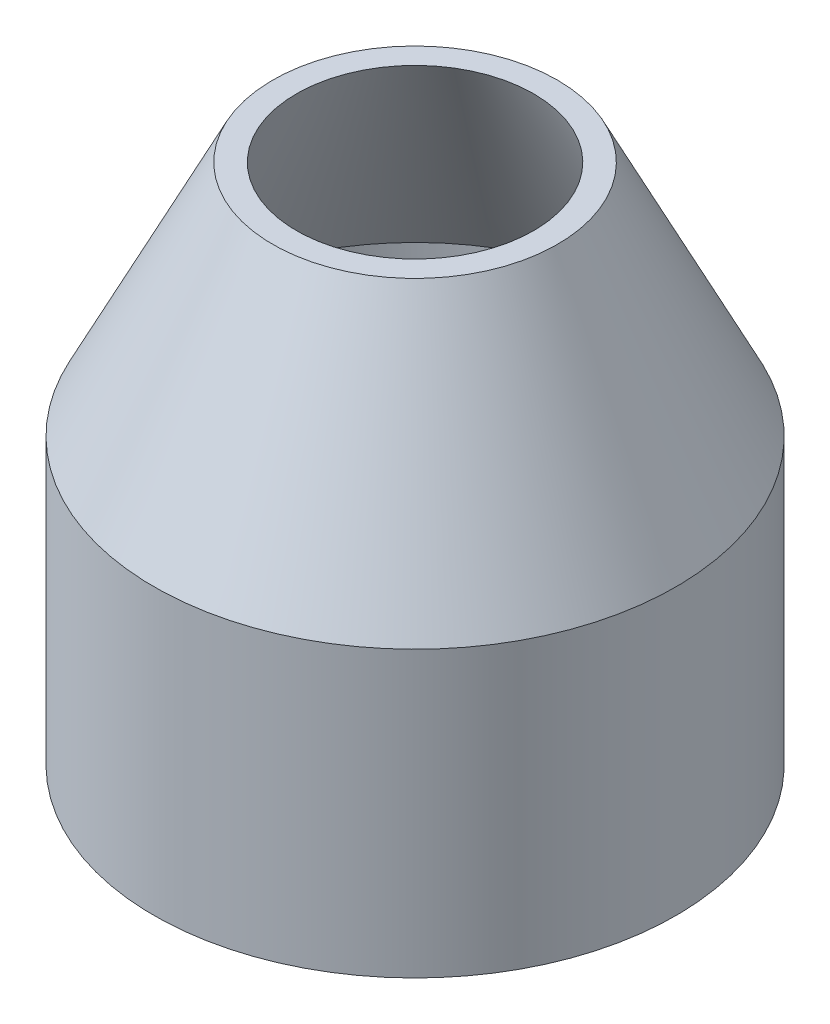
from build123d import *


with BuildPart() as part:
    # Sketch1 → Revolve2 (revolve)
    with BuildSketch(Plane.XY):
        Polygon((5.5, 0), (5.5, 6), (3, 11), (2.5, 11), (5, 6), (5, 0), align=None)
    revolve(axis=Axis((0, 0, 0), (0, 1, 0)))


solid = part.part
